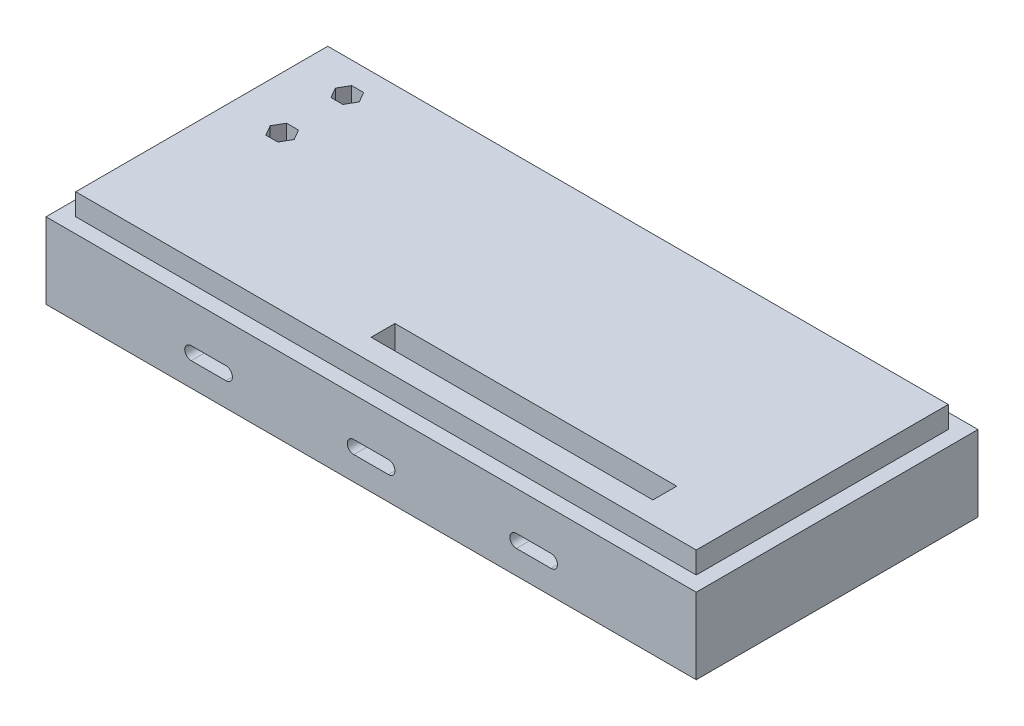
from build123d import *

# Parameters (mm, degrees)
SKETCH1_W           = 150
SKETCH1_H           = 65
BOSS_EXTRUDE1_DEPTH = 17.5
CUT_EXTRUDE1_DEPTH  = 66
SKETCH3_W           = 143.142
SKETCH3_H           = 58.142
BOSS_EXTRUDE2_DEPTH = 5
CUT_EXTRUDE2_DEPTH  = 6.5
SKETCH6_W           = 65
SKETCH6_H           = 5.5
CUT_EXTRUDE3_DEPTH  = 10


with BuildPart() as part:
    # Sketch1 → Boss-Extrude1 (new body)
    with BuildSketch(Plane(origin=(0, 0, 0), x_dir=(1, 0, 0), z_dir=(0, 1, 0))):
        Rectangle(SKETCH1_W, SKETCH1_H)
    extrude(amount=BOSS_EXTRUDE1_DEPTH)

    # Sketch2 → Cut-Extrude1 (cut, through all)
    with BuildSketch(Plane.XY.offset(32.5)):
        with BuildLine():
            Line((-4, 8.5), (4, 8.5))
            ThreePointArc((4, 8.5), (5.5, 7), (4, 5.5))
            Line((4, 5.5), (-4, 5.5))
            ThreePointArc((-4, 5.5), (-5.5, 7), (-4, 8.5))
        make_face()
        with BuildLine():
            Line((-41.5, 8.5), (-33.5, 8.5))
            ThreePointArc((-33.5, 8.5), (-32, 7), (-33.5, 5.5))
            Line((-33.5, 5.5), (-41.5, 5.5))
            ThreePointArc((-41.5, 5.5), (-43, 7), (-41.5, 8.5))
        make_face()
        with BuildLine():
            Line((33.5, 8.5), (41.5, 8.5))
            ThreePointArc((41.5, 8.5), (43, 7), (41.5, 5.5))
            Line((41.5, 5.5), (33.5, 5.5))
            ThreePointArc((33.5, 5.5), (32, 7), (33.5, 8.5))
        make_face()
    extrude(amount=-CUT_EXTRUDE1_DEPTH, mode=Mode.SUBTRACT)

    # Sketch3 → Boss-Extrude2 (add)
    with BuildSketch(Plane(origin=(0, 17.5, 0), x_dir=(1, 0, 0), z_dir=(0, 1, 0))):
        Rectangle(SKETCH3_W, SKETCH3_H)
    extrude(amount=BOSS_EXTRUDE2_DEPTH)

    # Sketch4 → Cut-Extrude2 (cut)
    with BuildSketch(Plane(origin=(0, 22.5, 0), x_dir=(1, 0, 0), z_dir=(0, 1, 0))):
        Polygon((-60.950867143, 23.961), (-62.330734287, 21.571), (-60.950867143, 19.181), (-58.191132857, 19.181), (-56.811265713, 21.571), (-58.191132857, 23.961), align=None)
        Polygon((-60.950867143, 8.941), (-62.330734287, 6.551), (-60.950867143, 4.161), (-58.191132857, 4.161), (-56.811265713, 6.551), (-58.191132857, 8.941), align=None)
    extrude(amount=-CUT_EXTRUDE2_DEPTH, mode=Mode.SUBTRACT)

    # Sketch6 → Cut-Extrude3 (cut)
    with BuildSketch(Plane(origin=(0, 22.5, 0), x_dir=(1, 0, 0), z_dir=(0, 1, 0))):
        with Locations((24.071, -21.321)):
            Rectangle(SKETCH6_W, SKETCH6_H)
    extrude(amount=-CUT_EXTRUDE3_DEPTH, mode=Mode.SUBTRACT)


solid = part.part
